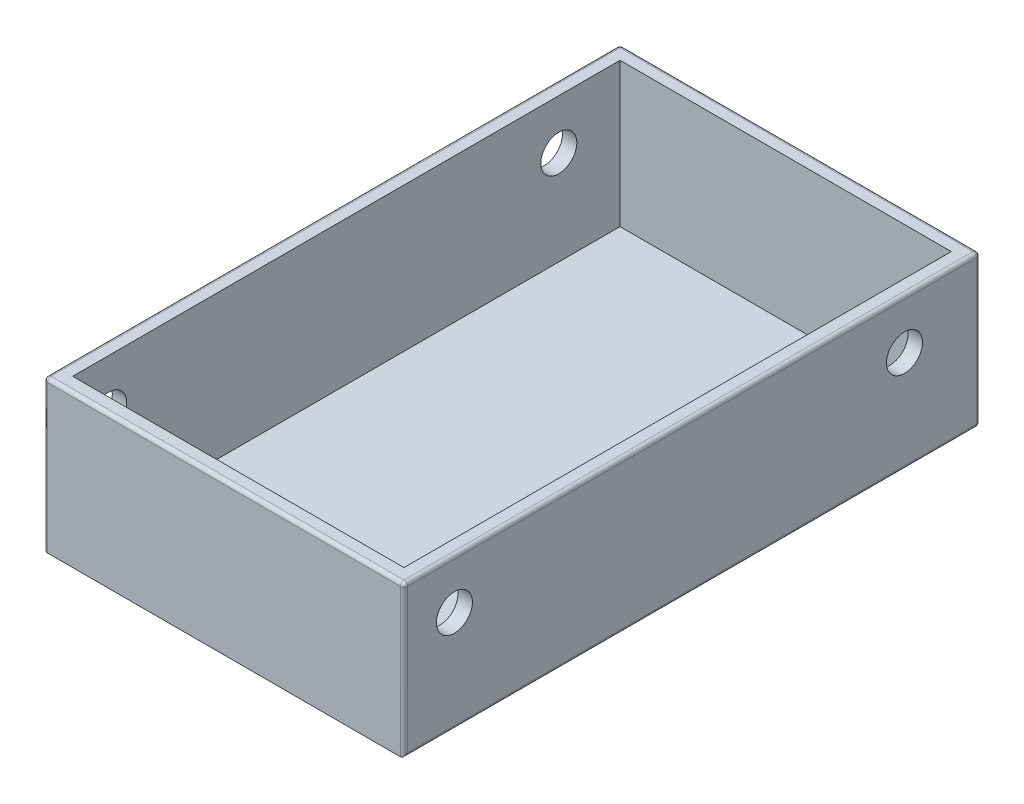
from build123d import *

# Parameters (mm, degrees)
SKETCH1_W           = 50
SKETCH1_H           = 80
SKETCH1_W_2         = 46
SKETCH1_H_2         = 76
BOSS_EXTRUDE1_DEPTH = 5
SKETCH1_2_W         = 46
SKETCH1_2_H         = 76
BOSS_EXTRUDE2_DEPTH = 5
SKETCH1_3_W         = 50
SKETCH1_3_H         = 80
SKETCH1_3_W_2       = 46
SKETCH1_3_H_2       = 76
BOSS_EXTRUDE3_DEPTH = 10
SKETCH1_4_W         = 46
SKETCH1_4_H         = 76
CUT_EXTRUDE2_DEPTH  = 49
SKETCH3_R           = 2.5
CUT_EXTRUDE3_DEPTH  = 49
BOSS_EXTRUDE4_START = -5
SKETCH1_5_W         = 46
SKETCH1_5_H         = 76
BOSS_EXTRUDE4_DEPTH = 1
BOSS_EXTRUDE5_START = -5
SKETCH1_6_W         = 50
SKETCH1_6_H         = 80
SKETCH1_6_W_2       = 46
SKETCH1_6_H_2       = 76
BOSS_EXTRUDE5_DEPTH = 1
SKETCH1_7_W         = 50
SKETCH1_7_H         = 80
SKETCH1_7_W_2       = 46
SKETCH1_7_H_2       = 76
BOSS_EXTRUDE6_DEPTH = 15
SKETCH3_2_R         = 2.5
CUT_EXTRUDE4_DEPTH  = 61
FILLET1_R           = 0.5


with BuildPart() as part:
    # Sketch1 → Boss-Extrude1 (new body)
    with BuildSketch(Plane(origin=(0, 0, 0), x_dir=(1, 0, 0), z_dir=(0, 1, 0))):
        with Locations((25, 40)):
            Rectangle(SKETCH1_W, SKETCH1_H)
        with Locations((25, 40)):
            Rectangle(SKETCH1_W_2, SKETCH1_H_2, mode=Mode.SUBTRACT)
    extrude(amount=-BOSS_EXTRUDE1_DEPTH)

    # Sketch1_2 → Boss-Extrude2 (add)
    with BuildSketch(Plane(origin=(0, 0, 0), x_dir=(1, 0, 0), z_dir=(0, 1, 0))):
        with Locations((25, 40)):
            Rectangle(SKETCH1_2_W, SKETCH1_2_H)
    extrude(amount=-BOSS_EXTRUDE2_DEPTH)

    # Sketch1_3 → Boss-Extrude3 (add)
    with BuildSketch(Plane(origin=(0, 0, 0), x_dir=(1, 0, 0), z_dir=(0, 1, 0))):
        with Locations((25, 40)):
            Rectangle(SKETCH1_3_W, SKETCH1_3_H)
        with Locations((25, 40)):
            Rectangle(SKETCH1_3_W_2, SKETCH1_3_H_2, mode=Mode.SUBTRACT)
    extrude(amount=BOSS_EXTRUDE3_DEPTH)

    # Sketch1_4 → Cut-Extrude2 (cut)
    with BuildSketch(Plane(origin=(0, 0, 0), x_dir=(1, 0, 0), z_dir=(0, 1, 0))):
        with Locations((25, 40)):
            Rectangle(SKETCH1_4_W, SKETCH1_4_H)
    extrude(amount=-CUT_EXTRUDE2_DEPTH, mode=Mode.SUBTRACT)

    # Sketch3 → Cut-Extrude3 (cut)
    with BuildSketch(Plane(origin=(50, 0, 0), x_dir=(0, 0, -1), z_dir=(1, 0, 0))):
        with Locations((7, 8.1)):
            Circle(SKETCH3_R)
        with Locations((69.5, 8.1)):
            Circle(SKETCH3_R)
    extrude(amount=-CUT_EXTRUDE3_DEPTH, mode=Mode.SUBTRACT)



with BuildPart() as body_2:
    # Sketch1_5 → Boss-Extrude4 (new body)
    with BuildSketch(Plane(origin=(0, 0, 0), x_dir=(1, 0, 0), z_dir=(0, 1, 0)).offset(BOSS_EXTRUDE4_START)):
        with Locations((25, 40)):
            Rectangle(SKETCH1_5_W, SKETCH1_5_H)
    extrude(amount=-BOSS_EXTRUDE4_DEPTH)


with BuildPart() as part_1:
    add(part.part)

    add(body_2.part)  # Boss-Extrude5 merges body 2
    # Sketch1_6 → Boss-Extrude5 (add)
    with BuildSketch(Plane(origin=(0, 0, 0), x_dir=(1, 0, 0), z_dir=(0, 1, 0)).offset(BOSS_EXTRUDE5_START)):
        with Locations((25, 40)):
            Rectangle(SKETCH1_6_W, SKETCH1_6_H)
        with Locations((25, 40)):
            Rectangle(SKETCH1_6_W_2, SKETCH1_6_H_2, mode=Mode.SUBTRACT)
    extrude(amount=-BOSS_EXTRUDE5_DEPTH)

    # Sketch1_7 → Boss-Extrude6 (add)
    with BuildSketch(Plane(origin=(0, 0, 0), x_dir=(1, 0, 0), z_dir=(0, 1, 0))):
        with Locations((25, 40)):
            Rectangle(SKETCH1_7_W, SKETCH1_7_H)
        with Locations((25, 40)):
            Rectangle(SKETCH1_7_W_2, SKETCH1_7_H_2, mode=Mode.SUBTRACT)
    extrude(amount=BOSS_EXTRUDE6_DEPTH)

    # Sketch3_2 → Cut-Extrude4 (cut)
    with BuildSketch(Plane(origin=(50, 0, 0), x_dir=(0, 0, -1), z_dir=(1, 0, 0))):
        with Locations((7, 8.1)):
            Circle(SKETCH3_2_R)
        with Locations((69.5, 8.1)):
            Circle(SKETCH3_2_R)
    extrude(amount=-CUT_EXTRUDE4_DEPTH, mode=Mode.SUBTRACT)

    # Fillet1
    fillet1_edges = [part_1.edges().sort_by_distance(p)[0] for p in [
        (50, 4.5, 0),
        (0, 4.5, 0),
        (0, 4.5, -80),
        (50, 4.5, -80),
        (25, -5, -2),
        (0, -6, -40),
        (50, -6, -40),
        (25, -6, -80),
        (25, 15, 0),
        (50, 15, -40),
        (0, 15, -40),
        (25, 15, -80),
    ]]
    fillet(fillet1_edges, radius=FILLET1_R)


solid = part_1.part
